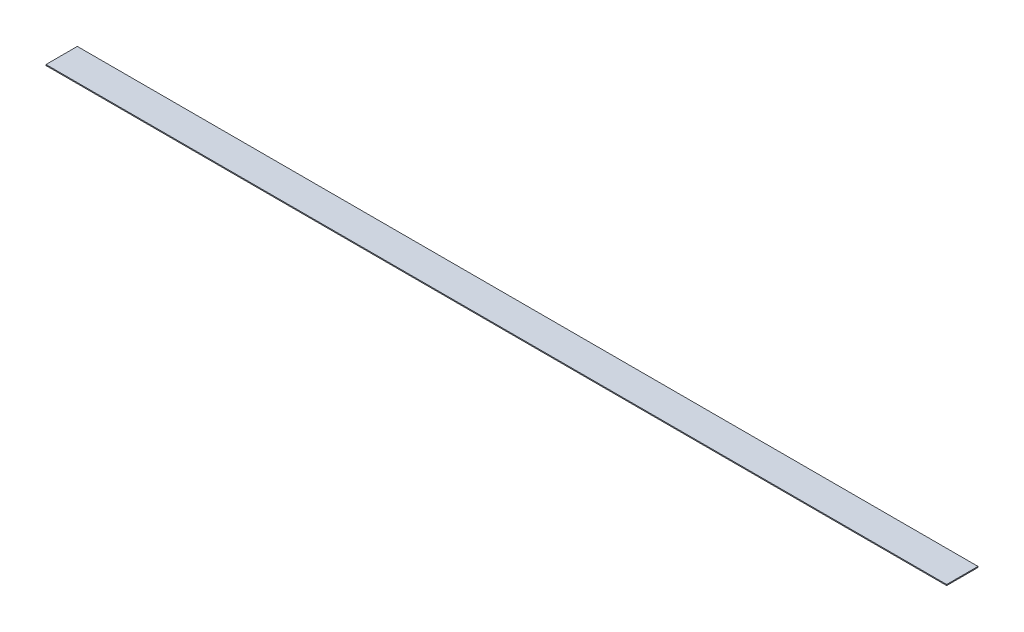
from build123d import *

# Parameters (mm, degrees)
SKETCH1_W           = 1460.5
SKETCH1_H           = 50.8
BOSS_EXTRUDE1_DEPTH = 1.5875


with BuildPart() as part:
    # Sketch1 → Boss-Extrude1 (new body)
    with BuildSketch(Plane(origin=(0, 0, 0), x_dir=(1, 0, 0), z_dir=(0, 1, 0))):
        with Locations((730.25, 25.4)):
            Rectangle(SKETCH1_W, SKETCH1_H)
    extrude(amount=BOSS_EXTRUDE1_DEPTH)


solid = part.part
